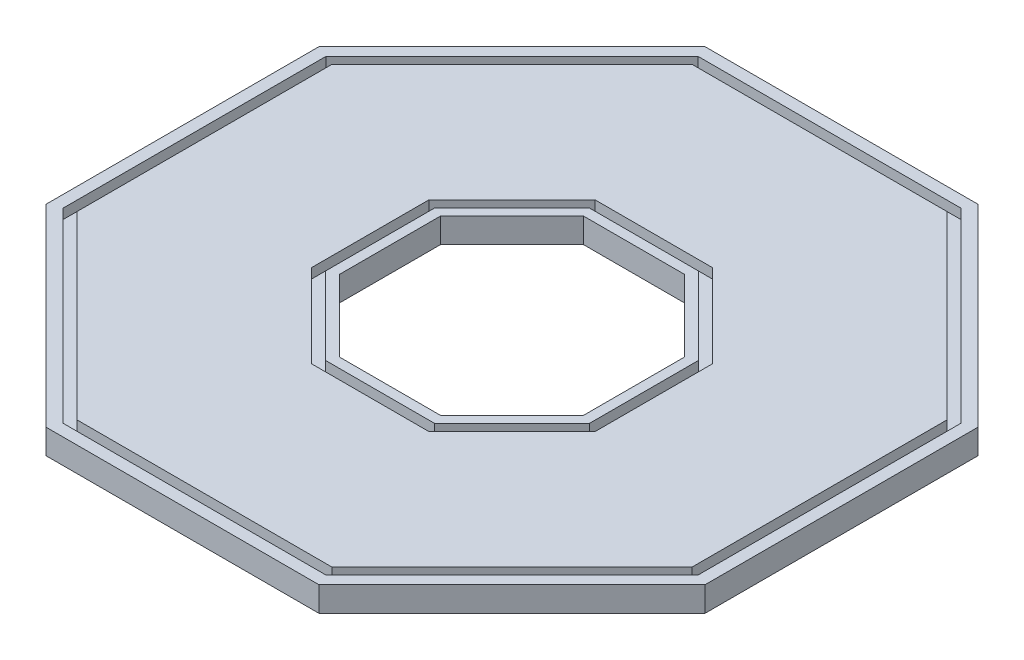
from build123d import *

# Parameters (mm, degrees)
EXTRUDE_1_DEPTH     = 2.5
CUT_EXTRUDE_1_DEPTH = 1
CUT_EXTRUDE_2_DEPTH = 3.8
CUT_EXTRUDE_3_DEPTH = 1


with BuildPart() as part:
    # 스케치1 → 보스-돌출1 (new body)
    with BuildSketch(Plane(origin=(0, 0, 0), x_dir=(1, 0, 0), z_dir=(0, 1, 0))):
        Polygon((-13.776603565, -33.25966317), (13.776603565, -33.25966317), (33.25966317, -13.776603565), (33.25966317, 13.776603565), (13.776603565, 33.25966317), (-13.776603565, 33.25966317), (-33.25966317, 13.776603565), (-33.25966317, -13.776603565), align=None)
    extrude(amount=EXTRUDE_1_DEPTH)

    # 스케치2 → 컷-돌출1 (cut)
    with BuildSketch(Plane(origin=(0, 2.5, 0), x_dir=(1, 0, 0), z_dir=(0, 1, 0))):
        Polygon((13.279115103, -32.058619778), (32.058619778, -13.279115103), (32.058619778, 13.279115103), (13.279115103, 32.058619778), (-13.279115103, 32.058619778), (-32.058619778, 13.279115103), (-32.058619778, -13.279115103), (-13.279115103, -32.058619778), align=None)
        Polygon((12.864901541, -31.058619778), (31.058619778, -12.864901541), (31.058619778, 12.864901541), (12.864901541, 31.058619778), (-12.864901541, 31.058619778), (-31.058619778, 12.864901541), (-31.058619778, -12.864901541), (-12.864901541, -31.058619778), align=None, mode=Mode.SUBTRACT)
    extrude(amount=-CUT_EXTRUDE_1_DEPTH, mode=Mode.SUBTRACT)

    # 스케치4 → 컷-돌출2 (cut)
    with BuildSketch(Plane(origin=(0, 2.5, 0), x_dir=(1, 0, 0), z_dir=(0, 1, 0))):
        Polygon((-5.103166077, -12.320132754), (5.103166077, -12.320132754), (12.320132754, -5.103166077), (12.320132754, 5.103166077), (5.103166077, 12.320132754), (-5.103166077, 12.320132754), (-12.320132754, 5.103166077), (-12.320132754, -5.103166077), align=None)
    extrude(amount=-CUT_EXTRUDE_2_DEPTH, mode=Mode.SUBTRACT)

    # 스케치4<3> → 컷-돌출3 (cut)
    with BuildSketch(Plane(origin=(0, 2.5, 0), x_dir=(1, 0, 0), z_dir=(0, 1, 0))):
        Polygon((-5.931593202, -14.320132754), (5.931593202, -14.320132754), (14.320132754, -5.931593202), (14.320132754, 5.931593202), (5.931593202, 14.320132754), (-5.931593202, 14.320132754), (-14.320132754, 5.931593202), (-14.320132754, -5.931593202), align=None)
        Polygon((13.320132754, -5.517379639), (5.517379639, -13.320132754), (-5.517379639, -13.320132754), (-13.320132754, -5.517379639), (-13.320132754, 5.517379639), (-5.517379639, 13.320132754), (5.517379639, 13.320132754), (13.320132754, 5.517379639), align=None, mode=Mode.SUBTRACT)
    extrude(amount=-CUT_EXTRUDE_3_DEPTH, mode=Mode.SUBTRACT)


solid = part.part
